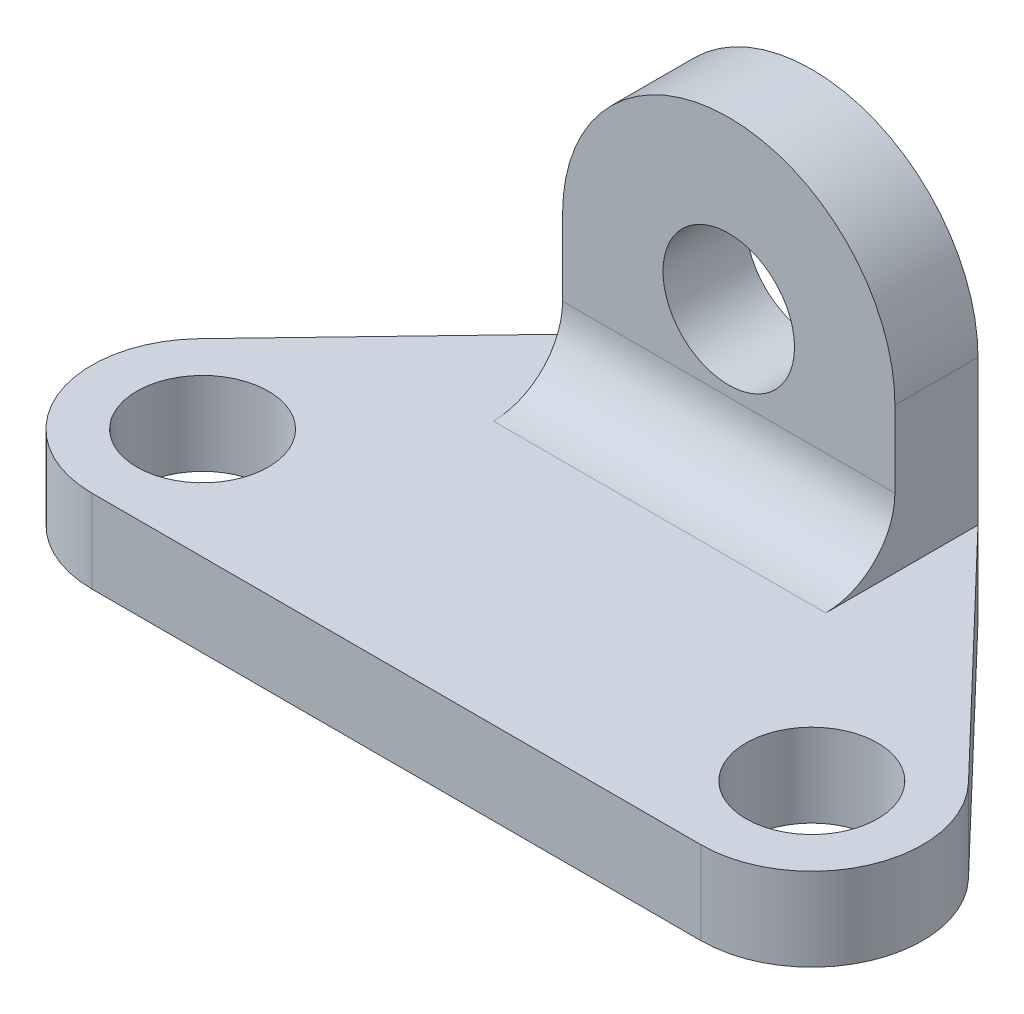
from build123d import *

# Parameters (mm, degrees)
EXTRUDE_3_DEPTH     = 12
SKETCH_10_R         = 9.5
CUT_EXTRUDE_4_DEPTH = 13
EXTRUDE_4_DEPTH     = 12
SKETCH_12_R         = 9.5
CUT_EXTRUDE_5_DEPTH = 12
FILLET_1_R          = 10


with BuildPart() as part:
    # 스케치8 → 보스-돌출3 (new body)
    with BuildSketch(Plane(origin=(0, 0, 0), x_dir=(1, 0, 0), z_dir=(0, 1, 0))):
        with BuildLine():
            Line((-44, -16), (44, -16))
            ThreePointArc((44, -16), (58.715829405, -6.280474897), (55.552799645, 11.069454384))
            Line((55.552799645, 11.069454384), (24, 44))
            Line((24, 44), (-24, 44))
            Line((-24, 44), (-55.552799645, 11.069454384))
            ThreePointArc((-55.552799645, 11.069454384), (-58.715829405, -6.280474897), (-44, -16))
        make_face()
    extrude(amount=EXTRUDE_3_DEPTH)

    # 스케치10 → 컷-돌출4 (cut, through all)
    with BuildSketch(Plane(origin=(0, 0, 0), x_dir=(1, 0, 0), z_dir=(0, 1, 0))):
        with Locations((-44, 0)):
            Circle(SKETCH_10_R)
        with Locations((44, 0)):
            Circle(SKETCH_10_R)
    extrude(amount=CUT_EXTRUDE_4_DEPTH, mode=Mode.SUBTRACT)

    # 스케치11 → 보스-돌출4 (add)
    with BuildSketch(Plane(origin=(0, 0, -44), x_dir=(-1, 0, 0), z_dir=(0, 0, -1))):
        with BuildLine():
            Line((-24, 33), (-24, 0))
            Line((-24, 0), (24, 0))
            Line((24, 0), (24, 33))
            ThreePointArc((24, 33), (0, 57), (-24, 33))
        make_face()
    extrude(amount=-EXTRUDE_4_DEPTH)

    # 스케치12 → 컷-돌출5 (cut)
    with BuildSketch(Plane.XY.offset(-32)):
        with Locations((0, 33)):
            Circle(SKETCH_12_R)
    extrude(amount=-CUT_EXTRUDE_5_DEPTH, mode=Mode.SUBTRACT)

    # 필렛1
    fillet_1_edges = [part.edges().sort_by_distance(p)[0] for p in [
        (0, 12, -32),
    ]]
    fillet(fillet_1_edges, radius=FILLET_1_R)


solid = part.part
